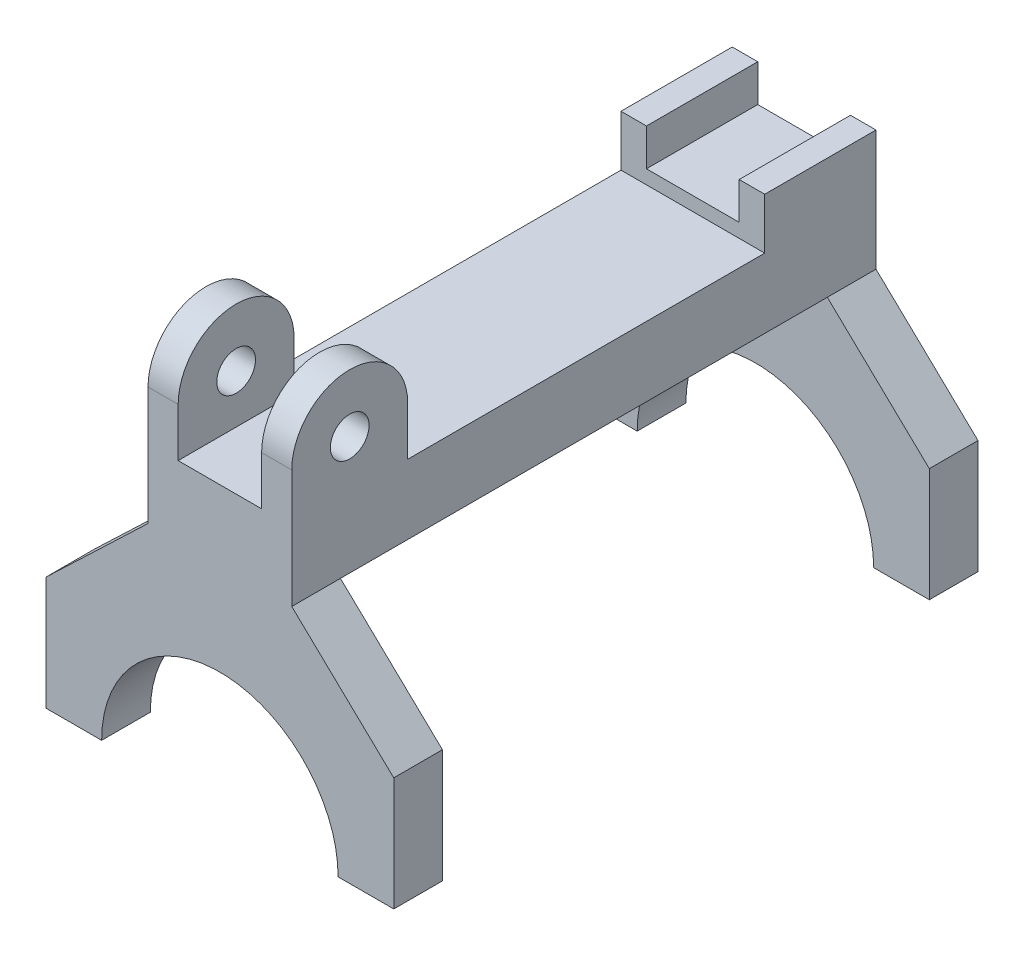
from build123d import *

# Parameters (mm, degrees)
BOSS_EXTRUDE1_DEPTH = 10.16
BOSS_EXTRUDE2_START = 9.144
SKETCH1_3_R         = 4.2418
BOSS_EXTRUDE2_DEPTH = 1.016
BOSS_EXTRUDE3_START = 10.16
SKETCH1_4_R         = 4.2418
SKETCH1_4_W         = 24.384
SKETCH1_4_H         = 8.128
SKETCH1_4_H_2       = 3.048
BOSS_EXTRUDE3_DEPTH = 5.588
BOSS_EXTRUDE4_DEPTH = 10.668
BOSS_EXTRUDE6_START = -128.016
BOSS_EXTRUDE6_DEPTH = 10.668


with BuildPart() as part:
    # Sketch1 → Boss-Extrude1 (new body)
    with BuildSketch(Plane(origin=(0, 0, 0), x_dir=(0, 0, -1), z_dir=(1, 0, 0))):
        Polygon((0, 15.24), (0, 0), (128.016, 0), (128.016, 18.288), (103.632, 18.288), (103.632, 15.24), align=None)
    boss_extrude1 = extrude(amount=BOSS_EXTRUDE1_DEPTH)

    # Sketch1_3 → Boss-Extrude2 (add)
    with BuildSketch(Plane(origin=(0, 0, 0), x_dir=(0, 0, -1), z_dir=(1, 0, 0)).offset(BOSS_EXTRUDE2_START)):
        with BuildLine():
            Line((0, 25.908), (0, 15.24))
            Line((0, 15.24), (25.4, 15.24))
            Line((25.4, 15.24), (25.4, 25.908))
            ThreePointArc((25.4, 25.908), (12.7, 38.608), (0, 25.908))
        make_face()
        with Locations((12.7, 25.908)):
            Circle(SKETCH1_3_R, mode=Mode.SUBTRACT)
    boss_extrude2 = extrude(amount=BOSS_EXTRUDE2_DEPTH)

    # Sketch1_4 → Boss-Extrude3 (add)
    with BuildSketch(Plane(origin=(0, 0, 0), x_dir=(0, 0, -1), z_dir=(1, 0, 0)).offset(BOSS_EXTRUDE3_START)):
        with BuildLine():
            Line((25.4, 15.24), (25.4, 25.908))
            ThreePointArc((25.4, 25.908), (12.7, 38.608), (0, 25.908))
            Line((0, 25.908), (0, 15.24))
            Line((0, 15.24), (25.4, 15.24))
        make_face()
        with Locations((12.7, 25.908)):
            Circle(SKETCH1_4_R, mode=Mode.SUBTRACT)
        Polygon((25.4, 15.24), (128.016, 15.24), (128.016, 0), (0, 0), (0, 15.24), align=None)
        with Locations((115.824, 22.352)):
            Rectangle(SKETCH1_4_W, SKETCH1_4_H)
        with Locations((115.824, 16.764)):
            Rectangle(SKETCH1_4_W, SKETCH1_4_H_2)
    boss_extrude3 = extrude(amount=BOSS_EXTRUDE3_DEPTH)

    # Mirror3: Boss-Extrude1, Boss-Extrude2, Boss-Extrude3 across plane
    add(boss_extrude1.mirror(Plane(origin=(0, 0, 0), x_dir=(0, 0, 1), z_dir=(1, 0, 0))))
    add(boss_extrude2.mirror(Plane(origin=(0, 0, 0), x_dir=(0, 0, 1), z_dir=(1, 0, 0))))
    add(boss_extrude3.mirror(Plane(origin=(0, 0, 0), x_dir=(0, 0, 1), z_dir=(1, 0, 0))))

    # Sketch2 → Boss-Extrude4 (add)
    with BuildSketch(Plane.XY):
        with BuildLine():
            Line((25.908, -46.228), (38.1, -46.228))
            Line((38.1, -46.228), (38.1, -21.336))
            Line((38.1, -21.336), (15.748, 0))
            Line((15.748, 0), (-15.748, 0))
            Line((-15.748, 0), (-38.1, -21.336))
            Line((-38.1, -21.336), (-38.1, -46.228))
            Line((-38.1, -46.228), (-25.908, -46.228))
            ThreePointArc((-25.908, -46.228), (0, -20.32), (25.908, -46.228))
        make_face()
    extrude(amount=-BOSS_EXTRUDE4_DEPTH)

    # Sketch2_2 → Boss-Extrude6 (add)
    with BuildSketch(Plane.XY.offset(BOSS_EXTRUDE6_START)):
        with BuildLine():
            ThreePointArc((-25.908, -46.228), (0, -20.32), (25.908, -46.228))
            Line((25.908, -46.228), (38.1, -46.228))
            Line((38.1, -46.228), (38.1, -21.336))
            Line((38.1, -21.336), (15.748, 0))
            Line((15.748, 0), (-15.748, 0))
            Line((-15.748, 0), (-38.1, -21.336))
            Line((-38.1, -21.336), (-38.1, -46.228))
            Line((-38.1, -46.228), (-25.908, -46.228))
        make_face()
    extrude(amount=BOSS_EXTRUDE6_DEPTH)


solid = part.part
